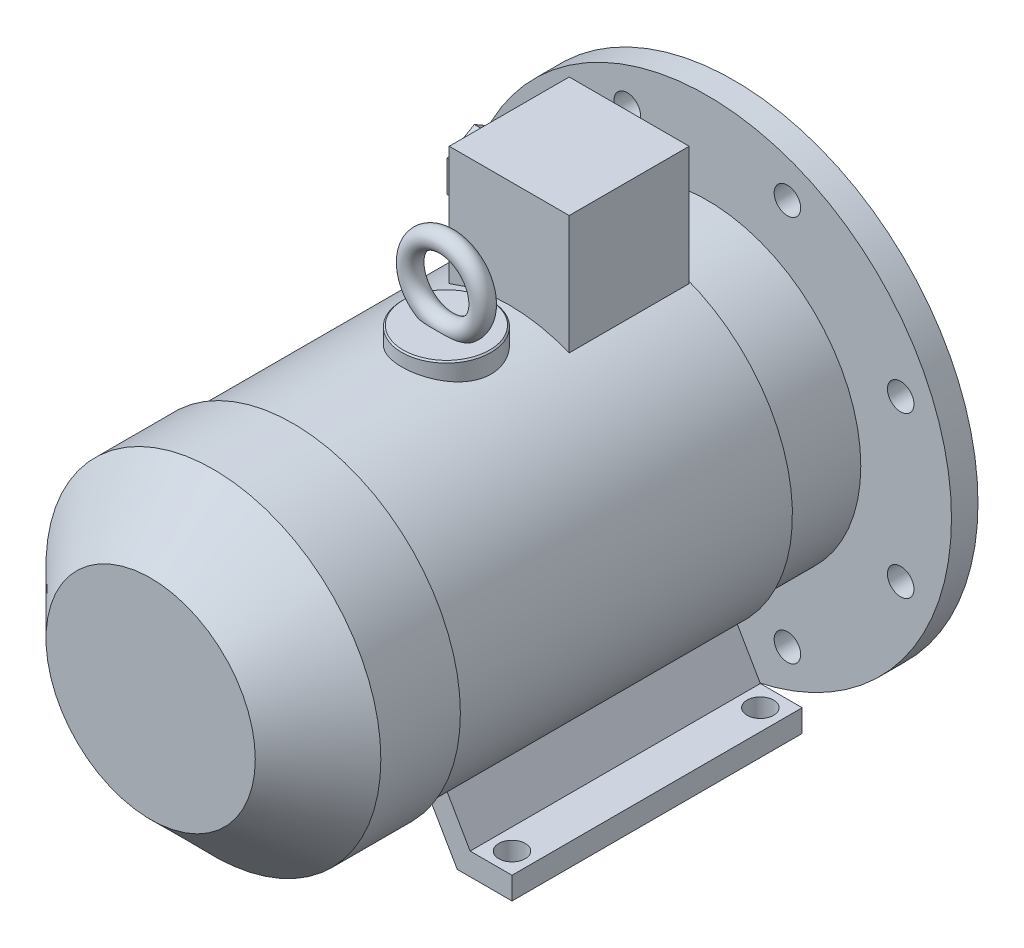
from build123d import *

# Parameters (mm, degrees)
SKETCH_1_R           = 19
EXTRUDE_1_DEPTH      = 80
SKETCH_2_W           = 8
SKETCH_2_H           = 8
EXTRUDE_2_DEPTH      = 0.1
EXTRUDE_2_DEPTH_BACK = 60
SKETCH_3_R           = 175
EXTRUDE_3_DEPTH      = 19
SKETCH_4_R           = 125
SKETCH_4_R_2         = 118
EXTRUDE_4_DEPTH      = 5
SKETCH_5_R           = 118
SKETCH_5_R_2         = 40
CUT_EXTRUDE_1_DEPTH  = 10
CHAMFER_1_SIZE       = 1
SKETCH_6_R           = 9.5
CUT_EXTRUDE_2_DEPTH  = 20
SKETCH_7_R           = 110
EXTRUDE_5_DEPTH      = 55
SKETCH_8_R           = 116
EXTRUDE_6_DEPTH      = 242
SKETCH_9_R           = 120
EXTRUDE_7_DEPTH      = 102
CHAMFER_2_SIZE       = 45
EXTRUDE_8_DEPTH      = 208
CUT_EXTRUDE_3_REACH  = 309
SKETCH_11_R          = 9.5
SKETCH_12_W          = 86
SKETCH_12_H          = 86
EXTRUDE_9_DEPTH      = 193
SKETCH_13_R          = 32
EXTRUDE_10_DEPTH     = 126
CHAMFER_3_SIZE       = 1
SKETCH_15_R          = 7
SKETCH_16_R          = 15
EXTRUDE_11_DEPTH     = 10
EXTRUDE_12_DEPTH     = 15
SKETCH_18_R          = 8
CUT_EXTRUDE_4_DEPTH  = 15


with BuildPart() as part:
    # Эскиз1 → Вытянуть1 (new body)
    with BuildSketch(Plane.XY):
        Circle(SKETCH_1_R)
    extrude(amount=EXTRUDE_1_DEPTH)

    # Эскиз2 → Вытянуть2 (add, two sides)
    with BuildSketch(Plane(origin=(0, 0, 0), x_dir=(-1, 0, 0), z_dir=(0, 0, -1))) as extrude_2_sk:
        with Locations((0, 18)):
            Rectangle(SKETCH_2_W, SKETCH_2_H)
    extrude(amount=EXTRUDE_2_DEPTH)
    extrude(extrude_2_sk.sketch, amount=-EXTRUDE_2_DEPTH_BACK)

    # Эскиз3 → Вытянуть3 (add)
    with BuildSketch(Plane.XY.offset(80)):
        Circle(SKETCH_3_R)
    extrude(amount=EXTRUDE_3_DEPTH)

    # Эскиз4 → Вытянуть4 (add)
    with BuildSketch(Plane(origin=(0, 0, 80), x_dir=(-1, 0, 0), z_dir=(0, 0, -1))):
        with Locations(Location((0, 0, 0), (0, 0, 180))):  # turned: the seam where the file's is
            Circle(SKETCH_4_R)
        Circle(SKETCH_4_R_2, mode=Mode.SUBTRACT)
    extrude(amount=EXTRUDE_4_DEPTH)

    # Эскиз5 → Вырез-Вытянуть1 (cut)
    with BuildSketch(Plane(origin=(0, 0, 80), x_dir=(-1, 0, 0), z_dir=(0, 0, -1))):
        Circle(SKETCH_5_R)
        Circle(SKETCH_5_R_2, mode=Mode.SUBTRACT)
    extrude(amount=-CUT_EXTRUDE_1_DEPTH, mode=Mode.SUBTRACT)

    # Фаска1
    chamfer_1_edges = [part.edges().sort_by_distance(p)[0] for p in [
        (-125, 0, 75),
        (40, 0, 80),
        (-11.937336386, -14.781745499, 0),
    ]]
    chamfer(chamfer_1_edges, length=CHAMFER_1_SIZE)

    # Эскиз6 → Вырез-Вытянуть2 (cut, through all)
    with BuildSketch(Plane(origin=(0, 0, 80), x_dir=(-1, 0, 0), z_dir=(0, 0, -1))):
        with Locations((-57.402514855, 138.581929877)):
            Circle(SKETCH_6_R)
        with Locations((57.402514855, 138.581929877)):
            Circle(SKETCH_6_R)
        with Locations((138.581929877, 57.402514855)):
            Circle(SKETCH_6_R)
        with Locations((138.581929877, -57.402514855)):
            Circle(SKETCH_6_R)
        with Locations((57.402514855, -138.581929877)):
            Circle(SKETCH_6_R)
        with Locations((-57.402514855, -138.581929877)):
            Circle(SKETCH_6_R)
        with Locations((-138.581929877, -57.402514855)):
            Circle(SKETCH_6_R)
        with Locations((-138.581929877, 57.402514855)):
            Circle(SKETCH_6_R)
    extrude(amount=-CUT_EXTRUDE_2_DEPTH, mode=Mode.SUBTRACT)

    # Эскиз7 → Вытянуть5 (add)
    with BuildSketch(Plane.XY.offset(99)):
        Circle(SKETCH_7_R)
    extrude(amount=EXTRUDE_5_DEPTH)

    # Эскиз8 → Вытянуть6 (add)
    with BuildSketch(Plane.XY.offset(154)):
        Circle(SKETCH_8_R)
    extrude(amount=EXTRUDE_6_DEPTH)

    # Эскиз9 → Вытянуть7 (add)
    with BuildSketch(Plane.XY.offset(396)):
        Circle(SKETCH_9_R)
    extrude(amount=EXTRUDE_7_DEPTH)

    # Фаска2
    chamfer_2_edges = [part.edges().sort_by_distance(p)[0] for p in [
        (-120, 0, 498),
    ]]
    chamfer(chamfer_2_edges, length=CHAMFER_2_SIZE)

    # Эскиз10 → Вытянуть8 (add)
    with BuildSketch(Plane(origin=(0, 0, 154), x_dir=(-1, 0, 0), z_dir=(0, 0, -1))):
        Polygon((-123, -132), (-83.762395693, -132), (-58.16412012, -87.662486121), (-72.020526581, -79.662486121), (-93, -116), (-123, -116), align=None)
        Polygon((123, -132), (83.762395693, -132), (58.16412012, -87.662486121), (72.020526581, -79.662486121), (93, -116), (123, -116), align=None)
    extrude(amount=-EXTRUDE_8_DEPTH)

    # Эскиз11 → Вырез-Вытянуть3 (cut, up to next)
    with BuildSketch(Plane.XZ.offset(132), mode=Mode.PRIVATE) as cut_extrude_3_sk1:
        with Locations((-108, 169)):
            Circle(SKETCH_11_R)
    cut_extrude_3_tool1 = extrude(cut_extrude_3_sk1.sketch, amount=-CUT_EXTRUDE_3_REACH, mode=Mode.PRIVATE) & part.part
    add(cut_extrude_3_tool1.solids().sort_by_distance((-108, -132, 169))[0], mode=Mode.SUBTRACT)
    # Эскиз11 → Вырез-Вытянуть3 (cut, up to next)
    with BuildSketch(Plane.XZ.offset(132), mode=Mode.PRIVATE) as cut_extrude_3_sk2:
        with Locations((108, 169)):
            Circle(SKETCH_11_R)
    cut_extrude_3_tool2 = extrude(cut_extrude_3_sk2.sketch, amount=-CUT_EXTRUDE_3_REACH, mode=Mode.PRIVATE) & part.part
    add(cut_extrude_3_tool2.solids().sort_by_distance((108, -132, 169))[0], mode=Mode.SUBTRACT)
    # Эскиз11 → Вырез-Вытянуть3 (cut, up to next)
    with BuildSketch(Plane.XZ.offset(132), mode=Mode.PRIVATE) as cut_extrude_3_sk3:
        with Locations((-108, 347)):
            Circle(SKETCH_11_R)
    cut_extrude_3_tool3 = extrude(cut_extrude_3_sk3.sketch, amount=-CUT_EXTRUDE_3_REACH, mode=Mode.PRIVATE) & part.part
    add(cut_extrude_3_tool3.solids().sort_by_distance((-108, -132, 347))[0], mode=Mode.SUBTRACT)
    # Эскиз11 → Вырез-Вытянуть3 (cut, up to next)
    with BuildSketch(Plane.XZ.offset(132), mode=Mode.PRIVATE) as cut_extrude_3_sk4:
        with Locations((108, 347)):
            Circle(SKETCH_11_R)
    cut_extrude_3_tool4 = extrude(cut_extrude_3_sk4.sketch, amount=-CUT_EXTRUDE_3_REACH, mode=Mode.PRIVATE) & part.part
    add(cut_extrude_3_tool4.solids().sort_by_distance((108, -132, 347))[0], mode=Mode.SUBTRACT)

    # Эскиз12 → Вытянуть9 (add)
    with BuildSketch(Plane(origin=(0, 0, 0), x_dir=(1, 0, 0), z_dir=(0, 1, 0))):
        with Locations((0, -198)):
            Rectangle(SKETCH_12_W, SKETCH_12_H)
    extrude(amount=EXTRUDE_9_DEPTH)

    # Эскиз13 → Вытянуть10 (add)
    with BuildSketch(Plane(origin=(0, 0, 0), x_dir=(1, 0, 0), z_dir=(0, 1, 0))):
        with Locations(Location((0, -286, 0), (0, 0, 90))):  # turned: the seam where the file's is
            Circle(SKETCH_13_R)
    extrude(amount=EXTRUDE_10_DEPTH)

    # Фаска3
    chamfer_3_edges = [part.edges().sort_by_distance(p)[0] for p in [
        (0, 126, 318),
    ]]
    chamfer(chamfer_3_edges, length=CHAMFER_3_SIZE)

    # По траектории1: sweep along a path in Эскиз14
    with BuildLine(Plane.XY.offset(286)) as sweep_1_path:
        CenterArc((0, 152), 26, 0, 360)
    # Эскиз15 → По траектории1 (sweep)
    with BuildSketch(Plane(origin=(0, 0, 0), x_dir=(0, 0, -1), z_dir=(1, 0, 0))):
        with Locations((-286, 178)):
            Circle(SKETCH_15_R)
    sweep(path=sweep_1_path.line)

    # Эскиз16 → Вытянуть11 (add)
    with BuildSketch(Plane.ZY.offset(43)):
        with Locations(Location((198, 150, 0), (0, 0, 180))):  # turned: the seam where the file's is
            Circle(SKETCH_16_R)
    extrude(amount=EXTRUDE_11_DEPTH)

    # Эскиз17 → Вытянуть12 (add)
    with BuildSketch(Plane.ZY.offset(53)):
        Polygon((198, 172.516660498), (178.5, 161.258330249), (178.5, 138.741669751), (198, 127.483339502), (217.5, 138.741669751), (217.5, 161.258330249), align=None)
    extrude(amount=EXTRUDE_12_DEPTH)

    # Эскиз18 → Вырез-Вытянуть4 (cut)
    with BuildSketch(Plane.ZY.offset(68)):
        with Locations((198, 150)):
            Circle(SKETCH_18_R)
    extrude(amount=-CUT_EXTRUDE_4_DEPTH, mode=Mode.SUBTRACT)


solid = part.part
